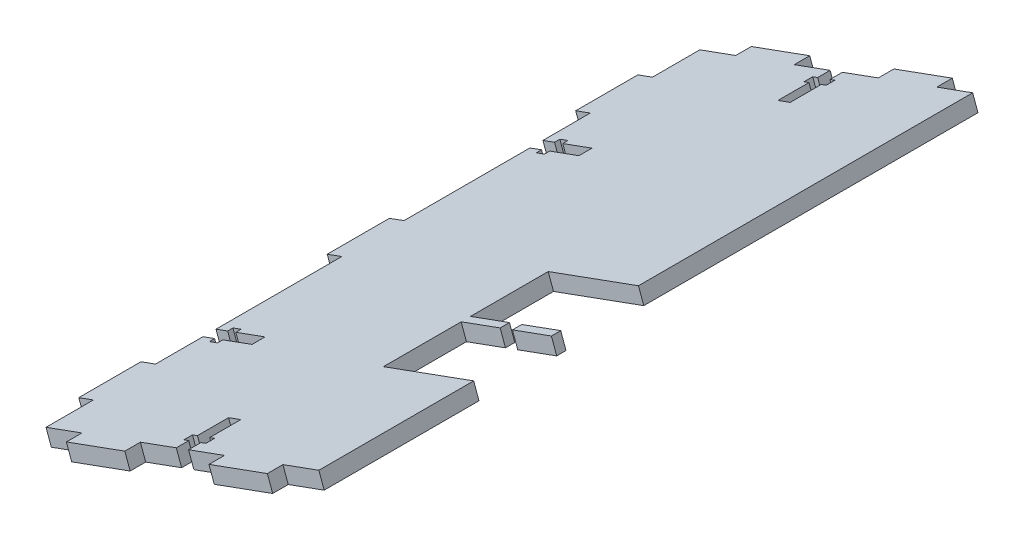
from build123d import *

# Parameters (mm, degrees)
BOSS_EXTRUDE1_DEPTH = 210.295833
CUT_EXTRUDE3_DEPTH  = 35.994480169
SKETCH5_W           = 20
SKETCH5_H           = 5
SKETCH5_W_2         = 5
SKETCH5_H_2         = 20
BOSS_EXTRUDE2_DEPTH = 5


with BuildPart() as part:
    # Sketch2 → Boss-Extrude1 (new body)
    with BuildSketch(Plane.XY.offset(2)):
        Polygon((-920.802501065, -330.765461908), (-919.09369882, -335.464397413), (-831.329066449, -303.548147303), (-833.037868694, -298.849211798), align=None)
    extrude(amount=BOSS_EXTRUDE1_DEPTH)

    # Sketch4 → Cut-Extrude3 (cut, through all)
    with BuildSketch(Plane(origin=(0.394814779, -1.085678105, 0), x_dir=(-0.939787101, -0.341760449, 0), z_dir=(0.341760449, -0.939787101, 0))):
        Polygon((929.606975284, -2), (933.806975284, -2), (933.806975284, -6), (935.506975284, -6), (935.506975284, -8.8), (933.806975284, -8.8), (933.806975284, -18.8), (929.606975284, -18.8), (929.606975284, -8.8), (927.906975284, -8.8), (927.906975284, -6), (929.606975284, -6), align=None)
        Polygon((978.400865988, -52.473958269), (978.400865988, -56.673958269), (974.400865988, -56.673958269), (974.400865988, -58.373958269), (971.600865988, -58.373958269), (971.600865988, -56.673958269), (961.600865988, -56.673958269), (961.600865988, -52.473958269), (971.600865988, -52.473958269), (971.600865988, -50.773958269), (974.400865988, -50.773958269), (974.400865988, -52.473958269), align=None)
        Polygon((933.806975284, -212.295833075), (929.606975284, -212.295833075), (929.606975284, -208.295833075), (927.906975284, -208.295833075), (927.906975284, -205.495833075), (929.606975284, -205.495833075), (929.606975284, -195.495833075), (933.806975284, -195.495833075), (933.806975284, -205.495833075), (935.506975284, -205.495833075), (935.506975284, -208.295833075), (933.806975284, -208.295833075), align=None)
        Polygon((974.400865988, -157.621874806), (974.400865988, -155.921874806), (971.600865988, -155.921874806), (971.600865988, -157.621874806), (961.600865988, -157.621874806), (961.600865988, -161.821874806), (971.600865988, -161.821874806), (971.600865988, -163.521874806), (974.400865988, -163.521874806), (974.400865988, -161.821874806), (978.400865988, -161.821874806), (978.400865988, -157.621874806), align=None)
        Polygon((885.01308458, -134.5), (898.356975284, -134.5), (898.356975284, -137.5), (885.01308458, -137.5), (885.01308458, -162.5), (915.900865988, -162.5), (915.900865988, -137.5), (902.556975284, -137.5), (902.556975284, -134.5), (915.900865988, -134.5), (915.900865988, -109.5), (885.01308458, -109.5), align=None)
    extrude(amount=-CUT_EXTRUDE3_DEPTH, mode=Mode.SUBTRACT)

    # Sketch5 → Boss-Extrude2 (add)
    with BuildSketch(Plane(origin=(0.394814779, -1.085678105, 0), x_dir=(0.939787101, 0.341760449, 0), z_dir=(0.341760449, -0.939787101, 0))):
        with Locations((-956.103920636, 214.795833075)):
            Rectangle(SKETCH5_W, SKETCH5_H)
        with Locations((-907.310029932, 214.795833075)):
            Rectangle(SKETCH5_W, SKETCH5_H)
        with Locations((-980.900865988, 187.058853941)):
            Rectangle(SKETCH5_W_2, SKETCH5_H_2)
        with Locations((-980.900865988, 107.147916538)):
            Rectangle(SKETCH5_W_2, SKETCH5_H_2)
        with Locations((-980.900865988, 27.236979134)):
            Rectangle(SKETCH5_W_2, SKETCH5_H_2)
        with Locations((-956.103920636, -0.5)):
            Rectangle(SKETCH5_W, SKETCH5_H)
        with Locations((-907.310029932, -0.5)):
            Rectangle(SKETCH5_W, SKETCH5_H)
    extrude(amount=-BOSS_EXTRUDE2_DEPTH)


solid = part.part
